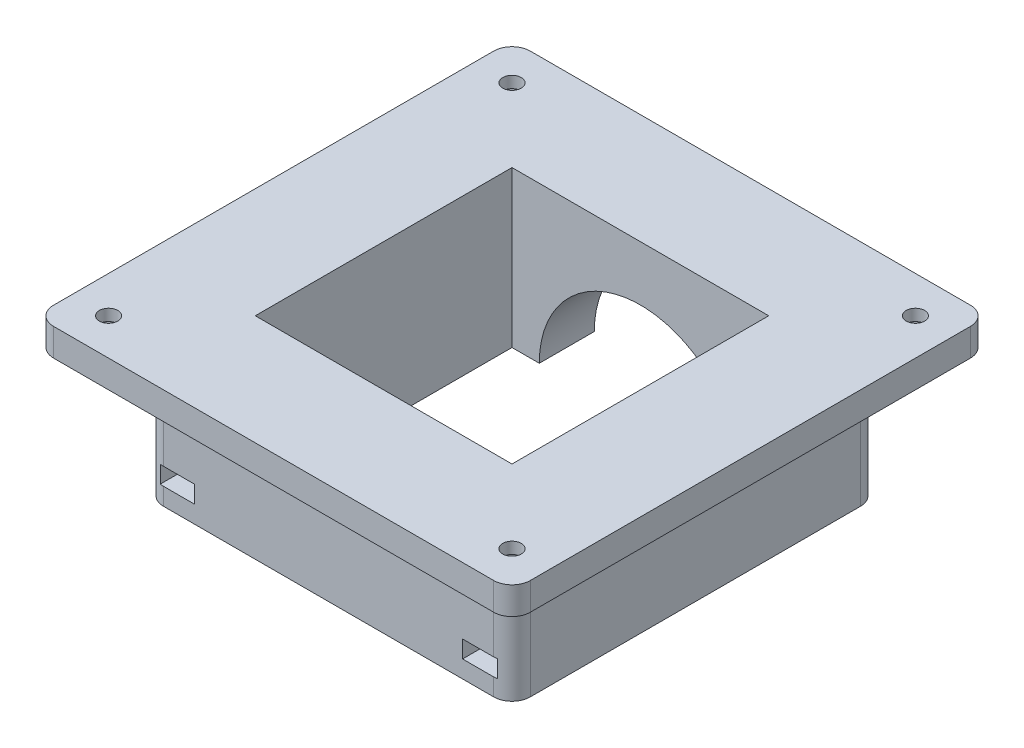
from build123d import *

# Parameters (mm, degrees)
SKETCH1_W               = 82.55
SKETCH1_H               = 82.55
SKETCH1_R               = 1.6
SKETCH1_W_2             = 44.45
SKETCH1_H_2             = 44.45
BOSS_EXTRUDE1_DEPTH     = 4.7625
SKETCH2_W               = 63.5
SKETCH2_H               = 63.5
SKETCH2_W_2             = 44.45
SKETCH2_H_2             = 44.45
BOSS_EXTRUDE2_DEPTH     = 6.35
SKETCH3_W               = 63.5
SKETCH3_H               = 63.5
SKETCH3_W_2             = 44.45
SKETCH3_H_2             = 44.45
BOSS_EXTRUDE3_DEPTH     = 15.875
CUT_EXTRUDE1_REACH      = 75.025
SKETCH4_R               = 17.5
FILLET1_R               = 3.175
CUT_EXTRUDE3_START      = -3
CUT_EXTRUDE3_DEPTH      = 3
SKETCH6_R               = 1.6
CUT_EXTRUDE4_DEPTH      = 7
MIRROR2_START           = -3
MIRROR2_COPY_1_DEPTH    = 3
MIRROR2_COPY_2_SKETCH_R = 1.6
MIRROR2_COPY_2_DEPTH    = 7
CUT_EXTRUDE5_DEPTH      = 2.7625


with BuildPart() as part:
    # Sketch1 → Boss-Extrude1 (new body)
    with BuildSketch(Plane(origin=(0, 0, 0), x_dir=(1, 0, 0), z_dir=(0, 1, 0))):
        Rectangle(SKETCH1_W, SKETCH1_H)
        with Locations((-34.925, 34.925)):
            Circle(SKETCH1_R, mode=Mode.SUBTRACT)
        with Locations((34.925, 34.925)):
            Circle(SKETCH1_R, mode=Mode.SUBTRACT)
        with Locations((34.925, -34.925)):
            Circle(SKETCH1_R, mode=Mode.SUBTRACT)
        with Locations((-34.925, -34.925)):
            Circle(SKETCH1_R, mode=Mode.SUBTRACT)
        Rectangle(SKETCH1_W_2, SKETCH1_H_2, mode=Mode.SUBTRACT)
    extrude(amount=BOSS_EXTRUDE1_DEPTH)

    # Sketch2 → Boss-Extrude2 (add)
    with BuildSketch(Plane.XZ):
        Rectangle(SKETCH2_W, SKETCH2_H)
        Rectangle(SKETCH2_W_2, SKETCH2_H_2, mode=Mode.SUBTRACT)
    extrude(amount=BOSS_EXTRUDE2_DEPTH)

    # Sketch3 → Boss-Extrude3 (add)
    with BuildSketch(Plane.XZ.offset(6.35)):
        Rectangle(SKETCH3_W, SKETCH3_H)
        Rectangle(SKETCH3_W_2, SKETCH3_H_2, mode=Mode.SUBTRACT)
    extrude(amount=BOSS_EXTRUDE3_DEPTH)

    # Sketch4 → Cut-Extrude1 (cut, up to next)
    with BuildSketch(Plane(origin=(0, 0, -31.75), x_dir=(-1, 0, 0), z_dir=(0, 0, -1)), mode=Mode.PRIVATE) as cut_extrude1_sk1:
        with Locations((0, -22.225)):
            Circle(SKETCH4_R)
    cut_extrude1_tool1 = extrude(cut_extrude1_sk1.sketch, amount=-CUT_EXTRUDE1_REACH, mode=Mode.PRIVATE) & part.part
    add(cut_extrude1_tool1.solids().sort_by_distance((0, -22.225, -31.75))[0], mode=Mode.SUBTRACT)

    # Fillet1
    fillet1_edges = [part.edges().sort_by_distance(p)[0] for p in [
        (31.75, -11.1125, -31.75),
        (31.75, -11.1125, 31.75),
        (-31.75, -11.1125, 31.75),
        (-31.75, -11.1125, -31.75),
        (41.275, 2.38125, 41.275),
        (-41.275, 2.38125, 41.275),
        (-41.275, 2.38125, -41.275),
        (41.275, 2.38125, -41.275),
    ]]
    fillet(fillet1_edges, radius=FILLET1_R)

    # Sketch5 → Cut-Extrude3 (cut)
    with BuildSketch(Plane.XZ.offset(22.225).offset(CUT_EXTRUDE3_START)):
        Polygon((-23.19375, -27.925800808), (-23.19375, -24.461699192), (-26.19375, -22.729648385), (-29.19375, -24.461699192), (-29.19375, -27.925800808), (-29.19375, -31.75), (-23.19375, -31.75), align=None)
    cut_extrude3 = extrude(amount=-CUT_EXTRUDE3_DEPTH, mode=Mode.SUBTRACT)

    # Sketch6 → Cut-Extrude4 (cut, through all)
    with BuildSketch(Plane(origin=(0, -16.225, 0), x_dir=(-1, 0, 0), z_dir=(0, -1, 0))):
        with Locations((26.19375, 26.19375)):
            Circle(SKETCH6_R)
    cut_extrude4 = extrude(amount=CUT_EXTRUDE4_DEPTH, mode=Mode.SUBTRACT)

    # Mirror1: Cut-Extrude3, Cut-Extrude4 across plane
    add(cut_extrude3.mirror(Plane(origin=(0, 0, 0), x_dir=(0, 0, 1), z_dir=(1, 0, 0))), mode=Mode.SUBTRACT)
    add(cut_extrude4.mirror(Plane(origin=(0, 0, 0), x_dir=(0, 0, 1), z_dir=(1, 0, 0))), mode=Mode.SUBTRACT)

    # Mirror2: Cut-Extrude4, Cut-Extrude3 across plane
    add(cut_extrude4.mirror(Plane.XY), mode=Mode.SUBTRACT)
    add(cut_extrude3.mirror(Plane.XY), mode=Mode.SUBTRACT)

    # Mirror2 copy 1 sketch → Mirror2 copy 1 (cut)
    with BuildSketch(Plane(origin=(0, -22.225, 0), x_dir=(-1, 0, 0), z_dir=(0, -1, 0)).offset(MIRROR2_START)):
        Polygon((-23.19375, -27.925800808), (-23.19375, -24.461699192), (-26.19375, -22.729648385), (-29.19375, -24.461699192), (-29.19375, -27.925800808), (-29.19375, -31.75), (-23.19375, -31.75), align=None)
    extrude(amount=-MIRROR2_COPY_1_DEPTH, mode=Mode.SUBTRACT)

    # Mirror2 copy 2 sketch → Mirror2 copy 2 (cut, through all)
    with BuildSketch(Plane.XZ.offset(16.225)):
        with Locations((26.19375, 26.19375)):
            Circle(MIRROR2_COPY_2_SKETCH_R)
    extrude(amount=MIRROR2_COPY_2_DEPTH, mode=Mode.SUBTRACT)

    # Sketch7 → Cut-Extrude5 (cut)
    with BuildSketch(Plane(origin=(0, 0, 0), x_dir=(-1, 0, 0), z_dir=(0, -1, 0))):
        Polygon((34.925, -31.460898385), (31.925, -33.192949192), (31.925, -36.657050808), (34.925, -38.389101615), (37.925, -36.657050808), (37.925, -33.192949192), align=None)
        Polygon((-37.925, -33.192949192), (-37.925, -36.657050808), (-34.925, -38.389101615), (-31.925, -36.657050808), (-31.925, -33.192949192), (-34.925, -31.460898385), align=None)
        Polygon((-37.925, 36.657050808), (-37.925, 33.192949192), (-34.925, 31.460898385), (-31.925, 33.192949192), (-31.925, 36.657050808), (-34.925, 38.389101615), align=None)
        Polygon((31.925, 36.657050808), (31.925, 33.192949192), (34.925, 31.460898385), (37.925, 33.192949192), (37.925, 36.657050808), (34.925, 38.389101615), align=None)
    extrude(amount=-CUT_EXTRUDE5_DEPTH, mode=Mode.SUBTRACT)


solid = part.part
